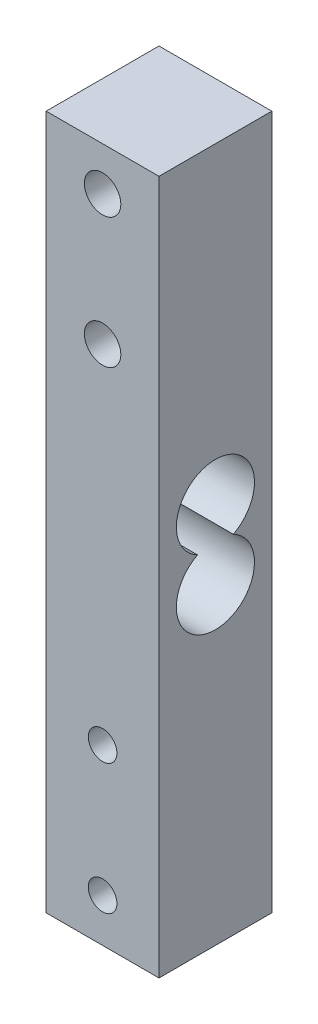
from build123d import *

# Parameters (mm, degrees)
SKETCH_1_W          = 13
SKETCH_1_H          = 80
SKETCH_1_R          = 2.1
SKETCH_1_R_2        = 1.65
EXTRUDE_1_DEPTH     = 13
CUT_EXTRUDE_4_DEPTH = 13
CUT_EXTRUDE_5_DEPTH = 3


with BuildPart() as part:
    # 草图1 → 凸台-拉伸1 (new body)
    with BuildSketch(Plane.XY):
        with Locations((0.560222304, -25.704710145)):
            Rectangle(SKETCH_1_W, SKETCH_1_H)
        with Locations((0.560222304, 9.295289855)):
            Circle(SKETCH_1_R, mode=Mode.SUBTRACT)
        with Locations((0.560222304, -5.704710145)):
            Circle(SKETCH_1_R, mode=Mode.SUBTRACT)
        with Locations((0.560222304, -60.704710145)):
            Circle(SKETCH_1_R_2, mode=Mode.SUBTRACT)
        with Locations((0.560222304, -45.704710145)):
            Circle(SKETCH_1_R_2, mode=Mode.SUBTRACT)
    extrude(amount=EXTRUDE_1_DEPTH)

    # 草图4 → 切除-拉伸4 (cut)
    with BuildSketch(Plane(origin=(7.060222304, 0, 0), x_dir=(0, 0, -1), z_dir=(1, 0, 0))):
        with BuildLine():
            ThreePointArc((-4.438447187, -25.704710145), (-6.5, -17.204710145), (-8.561552813, -25.704710145))
            ThreePointArc((-8.561552813, -25.704710145), (-6.5, -34.204710145), (-4.438447187, -25.704710145))
        make_face()
    extrude(amount=-CUT_EXTRUDE_4_DEPTH, mode=Mode.SUBTRACT)

    # 草图5 → 切除-拉伸5 (cut)
    with BuildSketch(Plane.XZ.offset(65.704710145)):
        Polygon((0, 10.380755621), (-2.765074416, 7.090643354), (-0.798384611, 7.090643354), (-0.798384611, 1.381735054), (0.79750081, 1.381735054), (0.79750081, 7.090643354), (2.925348038, 7.090643354), align=None)
    extrude(amount=-CUT_EXTRUDE_5_DEPTH, mode=Mode.SUBTRACT)


solid = part.part
